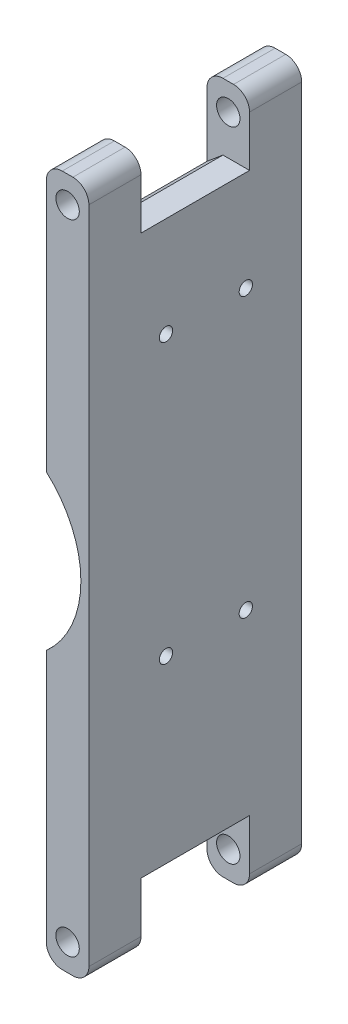
from build123d import *

# Parameters (mm, degrees)
SKETCH1_W             = 8
SKETCH1_H             = 130
BOSS_EXTRUDE1_DEPTH   = 40
SKETCH2_W             = 20.4
SKETCH2_H             = 25
CUT_EXTRUDE1_DEPTH    = 9
FILLET1_R             = 3
SKETCH3_R             = 2.2
CUT_EXTRUDE2_DEPTH    = 41
SKETCH4_R             = 19.5
CUT_EXTRUDE3_DEPTH    = 7.3
CUT_EXTRUDE5_REACH    = 10
SKETCH6_R             = 1.25
CHAMFER1_SIZE         = 3
CHAMFER1_SIZE2        = 2.517298894
CHAMFER1_PART_2_SIZE  = 3
CHAMFER1_PART_2_SIZE2 = 2.517298894


with BuildPart() as part:
    # Sketch1 → Boss-Extrude1 (new body)
    with BuildSketch(Plane.XY):
        Rectangle(SKETCH1_W, SKETCH1_H)
    extrude(amount=-BOSS_EXTRUDE1_DEPTH)

    # Sketch2 → Cut-Extrude1 (cut, through all)
    with BuildSketch(Plane(origin=(4, 0, 0), x_dir=(0, 0, -1), z_dir=(1, 0, 0))):
        with Locations((20, 65)):
            Rectangle(SKETCH2_W, SKETCH2_H)
        with Locations((20, -65)):
            Rectangle(SKETCH2_W, SKETCH2_H)
    extrude(amount=-CUT_EXTRUDE1_DEPTH, mode=Mode.SUBTRACT)

    # Fillet1
    fillet1_edges = [part.edges().sort_by_distance(p)[0] for p in [
        (4, 65, -4.9),
        (-4, 65, -4.9),
        (-4, -65, -4.9),
        (4, -65, -4.9),
        (4, -65, -35.1),
        (-4, -65, -35.1),
        (-4, 65, -35.1),
        (4, 65, -35.1),
    ]]
    fillet(fillet1_edges, radius=FILLET1_R)

    # Sketch3 → Cut-Extrude2 (cut, through all)
    with BuildSketch(Plane.XY):
        with Locations((0, 60)):
            Circle(SKETCH3_R)
        with Locations((0, -60)):
            Circle(SKETCH3_R)
    extrude(amount=-CUT_EXTRUDE2_DEPTH, mode=Mode.SUBTRACT)

    # Sketch4 → Cut-Extrude3 (cut)
    with BuildSketch(Plane.XY):
        with Locations((-17, 0)):
            Circle(SKETCH4_R)
    extrude(amount=-CUT_EXTRUDE3_DEPTH, mode=Mode.SUBTRACT)

    # Sketch6 → Cut-Extrude5 (cut, up to next)
    with BuildSketch(Plane.ZY.offset(4), mode=Mode.PRIVATE) as cut_extrude5_sk1:
        with Locations((-29.5, 33.7)):
            Circle(SKETCH6_R)
    cut_extrude5_tool1 = extrude(cut_extrude5_sk1.sketch, amount=-CUT_EXTRUDE5_REACH, mode=Mode.PRIVATE) & part.part
    add(cut_extrude5_tool1.solids().sort_by_distance((-4, 33.7, -29.5))[0], mode=Mode.SUBTRACT)
    # Sketch6 → Cut-Extrude5 (cut, up to next)
    with BuildSketch(Plane.ZY.offset(4), mode=Mode.PRIVATE) as cut_extrude5_sk2:
        with Locations((-29.5, -18.7)):
            Circle(SKETCH6_R)
    cut_extrude5_tool2 = extrude(cut_extrude5_sk2.sketch, amount=-CUT_EXTRUDE5_REACH, mode=Mode.PRIVATE) & part.part
    add(cut_extrude5_tool2.solids().sort_by_distance((-4, -18.7, -29.5))[0], mode=Mode.SUBTRACT)
    # Sketch6 → Cut-Extrude5 (cut, up to next)
    with BuildSketch(Plane.ZY.offset(4), mode=Mode.PRIVATE) as cut_extrude5_sk3:
        with Locations((-14.5, 33.7)):
            Circle(SKETCH6_R)
    cut_extrude5_tool3 = extrude(cut_extrude5_sk3.sketch, amount=-CUT_EXTRUDE5_REACH, mode=Mode.PRIVATE) & part.part
    add(cut_extrude5_tool3.solids().sort_by_distance((-4, 33.7, -14.5))[0], mode=Mode.SUBTRACT)
    # Sketch6 → Cut-Extrude5 (cut, up to next)
    with BuildSketch(Plane.ZY.offset(4), mode=Mode.PRIVATE) as cut_extrude5_sk4:
        with Locations((-14.5, -18.7)):
            Circle(SKETCH6_R)
    cut_extrude5_tool4 = extrude(cut_extrude5_sk4.sketch, amount=-CUT_EXTRUDE5_REACH, mode=Mode.PRIVATE) & part.part
    add(cut_extrude5_tool4.solids().sort_by_distance((-4, -18.7, -14.5))[0], mode=Mode.SUBTRACT)

    # Chamfer1
    chamfer1_edges = [part.edges().sort_by_distance(p)[0] for p in [
        (-4, 52.5, -20),
    ]]
    chamfer1_side = [part.faces().sort_by_distance(p)[0] for p in [
        (0, 52.5, -20),
    ]]
    chamfer(chamfer1_edges, length=CHAMFER1_SIZE, length2=CHAMFER1_SIZE2, reference=chamfer1_side[0])

    # Chamfer1 part 2
    chamfer1_part_2_edges = [part.edges().sort_by_distance(p)[0] for p in [
        (-4, -52.5, -20),
    ]]
    chamfer1_part_2_side = [part.faces().sort_by_distance(p)[0] for p in [
        (0, -52.5, -20),
    ]]
    chamfer(chamfer1_part_2_edges, length=CHAMFER1_PART_2_SIZE, length2=CHAMFER1_PART_2_SIZE2, reference=chamfer1_part_2_side[0])


solid = part.part
